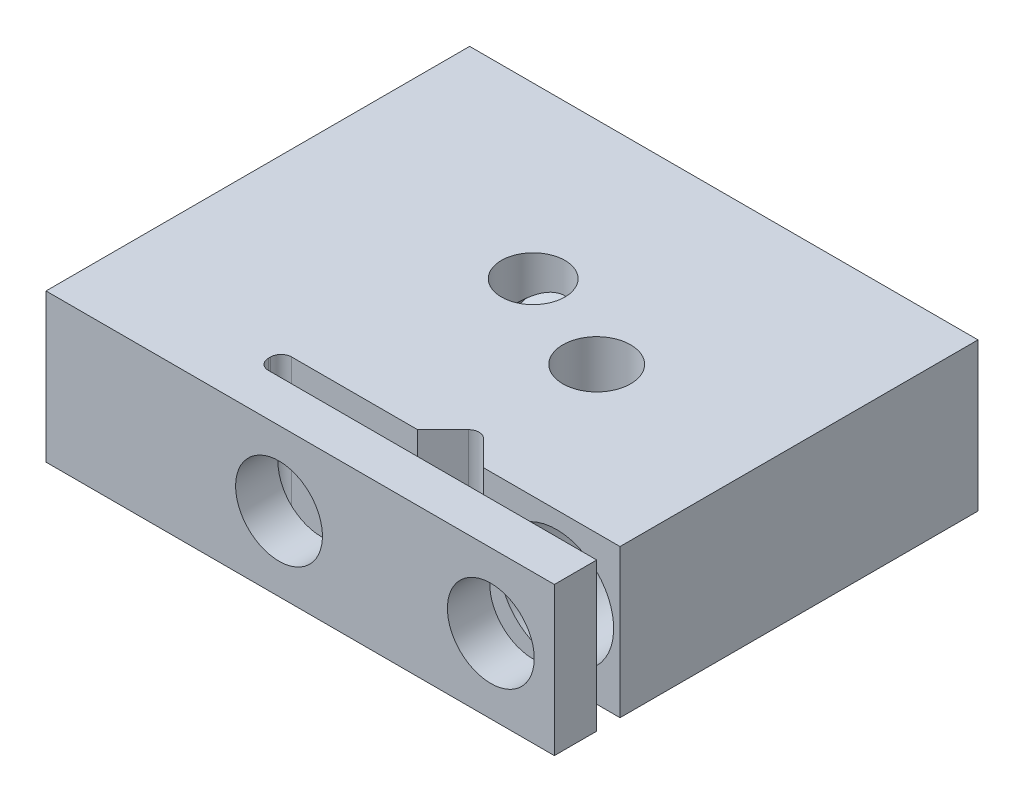
from build123d import *

# Parameters (mm, degrees)
SKETCH1_W                      = 12
SKETCH1_H                      = 10
BOSS_EXTRUDE1_DEPTH            = 3.5
CUT_EXTRUDE1_DEPTH             = 3.5
M2_5_CLEARANCE_HOLE1_D         = 2.7
M2_5_CLEARANCE_HOLE1_DEPTH     = 8.45
M2_5_TAPPED_HOLE1_D            = 2.05
M2_5_TAPPED_HOLE1_DEPTH        = 1
F_1_5_1_5_DIAMETER_HOLE1_D     = 1.5
F_1_5_1_5_DIAMETER_HOLE1_DEPTH = 3.5
M2_5_TAPPED_HOLE2_D            = 2.05
M2_5_TAPPED_HOLE4_D            = 2.05
M2_5_TAPPED_HOLE4_DEPTH        = 5
M2_5_TAPPED_HOLE4_TIP          = 0.615882135
M2_TAPPED_HOLE1_D              = 1.6


with BuildPart() as part:
    # Sketch1 → Boss-Extrude1 (new body)
    with BuildSketch(Plane(origin=(0, 0, 0), x_dir=(1, 0, 0), z_dir=(0, 1, 0))):
        Rectangle(SKETCH1_W, SKETCH1_H)
    extrude(amount=BOSS_EXTRUDE1_DEPTH)

    # Sketch2 → Cut-Extrude1 (cut)
    with BuildSketch(Plane(origin=(0, 3.5, 0), x_dir=(1, 0, 0), z_dir=(0, 1, 0))):
        with BuildLine():
            Line((2.777817459, -3.45), (2.176776695, -2.848959236))
            ThreePointArc((2.176776695, -2.848959236), (2, -2.775735931), (1.823223305, -2.848959236))
            Line((1.823223305, -2.848959236), (1.222182541, -3.45))
            Line((1.222182541, -3.45), (-1.75, -3.45))
            ThreePointArc((-1.75, -3.45), (-1.926776695, -3.523223305), (-2, -3.7))
            Line((-2, -3.7), (-2, -3.75))
            ThreePointArc((-2, -3.75), (-1.926776695, -3.926776695), (-1.75, -4))
            Line((-1.75, -4), (6, -4))
            Line((6, -4), (6, -3.45))
            Line((6, -3.45), (2.777817459, -3.45))
        make_face()
    extrude(amount=-CUT_EXTRUDE1_DEPTH, mode=Mode.SUBTRACT)

    # M2.5 Clearance Hole1
    with Locations(Plane(origin=(0, 0, -5), x_dir=(-1, 0, 0), z_dir=(0, 0, -1))):
        with Locations((-4.5, 1.75)):
            Hole(M2_5_CLEARANCE_HOLE1_D / 2, depth=M2_5_CLEARANCE_HOLE1_DEPTH)

    # M2.5 Tapped Hole1
    with Locations(Plane.XY.offset(5)):
        with Locations((4.5, 1.75)):
            Hole(M2_5_TAPPED_HOLE1_D / 2, depth=M2_5_TAPPED_HOLE1_DEPTH)

    # Ø1.5 (1.5) Diameter Hole1
    with Locations(Plane(origin=(0, 3.5, 0), x_dir=(1, 0, 0), z_dir=(0, 1, 0))):
        with Locations((-0.5, 1)):
            Hole(F_1_5_1_5_DIAMETER_HOLE1_D / 2, depth=F_1_5_1_5_DIAMETER_HOLE1_DEPTH)

    # M2.5 Tapped Hole2 (through all)
    with Locations(Plane(origin=(0, 0, -5), x_dir=(-1, 0, 0), z_dir=(0, 0, -1))):
        with Locations((0.5, 1.75)):
            Hole(M2_5_TAPPED_HOLE2_D / 2)

    # M2.5 Tapped Hole4
    with Locations(Plane.ZY.offset(6)):
        with Locations((-2.5, 1.75), (2.5, 1.75)):
            Hole(M2_5_TAPPED_HOLE4_D / 2, depth=M2_5_TAPPED_HOLE4_DEPTH)
            with Locations((0, 0, -(M2_5_TAPPED_HOLE4_DEPTH + M2_5_TAPPED_HOLE4_TIP / 2))):  # 118° drill point
                Cone(0, M2_5_TAPPED_HOLE4_D / 2, M2_5_TAPPED_HOLE4_TIP, mode=Mode.SUBTRACT)

    # M2 Tapped Hole1 (through all)
    with Locations(Plane(origin=(0, 0, 0), x_dir=(-1, 0, 0), z_dir=(0, -1, 0))):
        with Locations((-2, 0)):
            Hole(M2_TAPPED_HOLE1_D / 2)


solid = part.part
